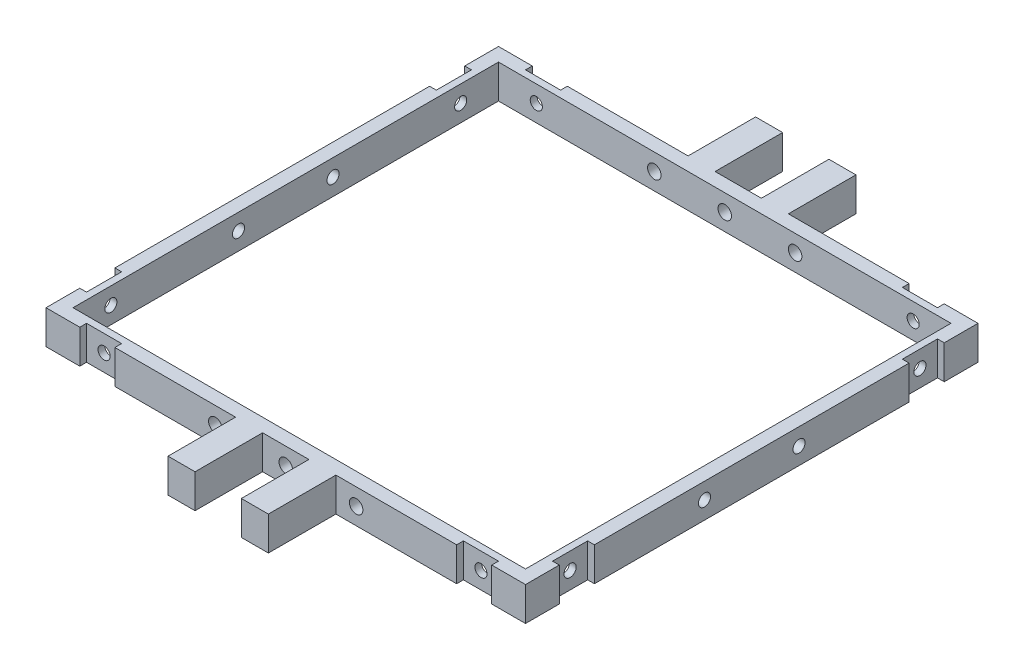
from build123d import *

# Parameters (mm, degrees)
SKETCH1_W           = 71
SKETCH1_H           = 67
SKETCH1_W_2         = 67
SKETCH1_H_2         = 63
BOSS_EXTRUDE1_DEPTH = 5
SKETCH2_R           = 0.9
CUT_EXTRUDE1_DEPTH  = 121
SKETCH3_R           = 1
CUT_EXTRUDE2_DEPTH  = 90
SKETCH4_W           = 4
SKETCH4_H           = 5
BOSS_EXTRUDE2_DEPTH = 10
SKETCH5_R           = 1
CUT_EXTRUDE3_DEPTH  = 109
SKETCH9_W           = 5.2
SKETCH9_H           = 5
CUT_EXTRUDE6_DEPTH  = 1
SKETCH10_W          = 5.2
SKETCH10_H          = 5
CUT_EXTRUDE7_DEPTH  = 1
SKETCH11_R          = 0.9
CUT_EXTRUDE8_DEPTH  = 81
SKETCH12_R          = 0.9
CUT_EXTRUDE9_DEPTH  = 81


with BuildPart() as part:
    # Sketch1 → Boss-Extrude1 (new body)
    with BuildSketch(Plane(origin=(0, 0, 0), x_dir=(1, 0, 0), z_dir=(0, 1, 0))):
        Rectangle(SKETCH1_W, SKETCH1_H)
        Rectangle(SKETCH1_W_2, SKETCH1_H_2, mode=Mode.SUBTRACT)
    extrude(amount=BOSS_EXTRUDE1_DEPTH)

    # Sketch2 → Cut-Extrude1 (cut)
    with BuildSketch(Plane(origin=(35.5, 0, 0), x_dir=(0, 0, -1), z_dir=(1, 0, 0))):
        with Locations((-6.999701476, 2.591425228)):
            Circle(SKETCH2_R)
        with Locations((7, 2.5)):
            Circle(SKETCH2_R)
    extrude(amount=-CUT_EXTRUDE1_DEPTH, mode=Mode.SUBTRACT)

    # Sketch3 → Cut-Extrude2 (cut)
    with BuildSketch(Plane.XY.offset(33.5)):
        with Locations((0, 2.5)):
            Circle(SKETCH3_R)
    extrude(amount=-CUT_EXTRUDE2_DEPTH, mode=Mode.SUBTRACT)

    # Sketch4 → Boss-Extrude2 (add)
    with BuildSketch(Plane.XY.offset(33.5)):
        with Locations((5.425, 2.5)):
            Rectangle(SKETCH4_W, SKETCH4_H)
        with Locations((-5.428919328, 2.5)):
            Rectangle(SKETCH4_W, SKETCH4_H)
    boss_extrude2 = extrude(amount=BOSS_EXTRUDE2_DEPTH)

    # Mirror1: Boss-Extrude2 across plane
    add(boss_extrude2.mirror(Plane.XY))

    # Sketch5 → Cut-Extrude3 (cut)
    with BuildSketch(Plane.XY.offset(33.5)):
        with Locations((-10.428919328, 2.5)):
            Circle(SKETCH5_R)
        with Locations((10.425, 2.5)):
            Circle(SKETCH5_R)
    extrude(amount=-CUT_EXTRUDE3_DEPTH, mode=Mode.SUBTRACT)

    # Sketch9 → Cut-Extrude6 (cut)
    with BuildSketch(Plane.XY.offset(33.5)):
        with Locations((-27.9, 2.5)):
            Rectangle(SKETCH9_W, SKETCH9_H)
        with Locations((27.9, 2.5)):
            Rectangle(SKETCH9_W, SKETCH9_H)
    cut_extrude6 = extrude(amount=-CUT_EXTRUDE6_DEPTH, mode=Mode.SUBTRACT)

    # Sketch10 → Cut-Extrude7 (cut)
    with BuildSketch(Plane(origin=(35.5, 0, 0), x_dir=(0, 0, -1), z_dir=(1, 0, 0))):
        with Locations((-25.9, 2.5)):
            Rectangle(SKETCH10_W, SKETCH10_H)
        with Locations((25.9, 2.5)):
            Rectangle(SKETCH10_W, SKETCH10_H)
    cut_extrude7 = extrude(amount=-CUT_EXTRUDE7_DEPTH, mode=Mode.SUBTRACT)

    # Mirror2: Cut-Extrude7 across plane
    add(cut_extrude7.mirror(Plane(origin=(0, 0, 0), x_dir=(0, 0, 1), z_dir=(1, 0, 0))), mode=Mode.SUBTRACT)

    # Mirror3: Cut-Extrude6 across plane
    add(cut_extrude6.mirror(Plane.XY), mode=Mode.SUBTRACT)

    # Sketch11 → Cut-Extrude8 (cut)
    with BuildSketch(Plane(origin=(34.5, 0, 0), x_dir=(0, 0, -1), z_dir=(1, 0, 0))):
        with Locations((25.9, 2.5)):
            Circle(SKETCH11_R)
        with Locations((-25.9, 2.5)):
            Circle(SKETCH11_R)
    extrude(amount=-CUT_EXTRUDE8_DEPTH, mode=Mode.SUBTRACT)

    # Sketch12 → Cut-Extrude9 (cut)
    with BuildSketch(Plane.XY.offset(32.5)):
        with Locations((27.9, 2.5)):
            Circle(SKETCH12_R)
        with Locations((-27.9, 2.5)):
            Circle(SKETCH12_R)
    extrude(amount=-CUT_EXTRUDE9_DEPTH, mode=Mode.SUBTRACT)


solid = part.part
